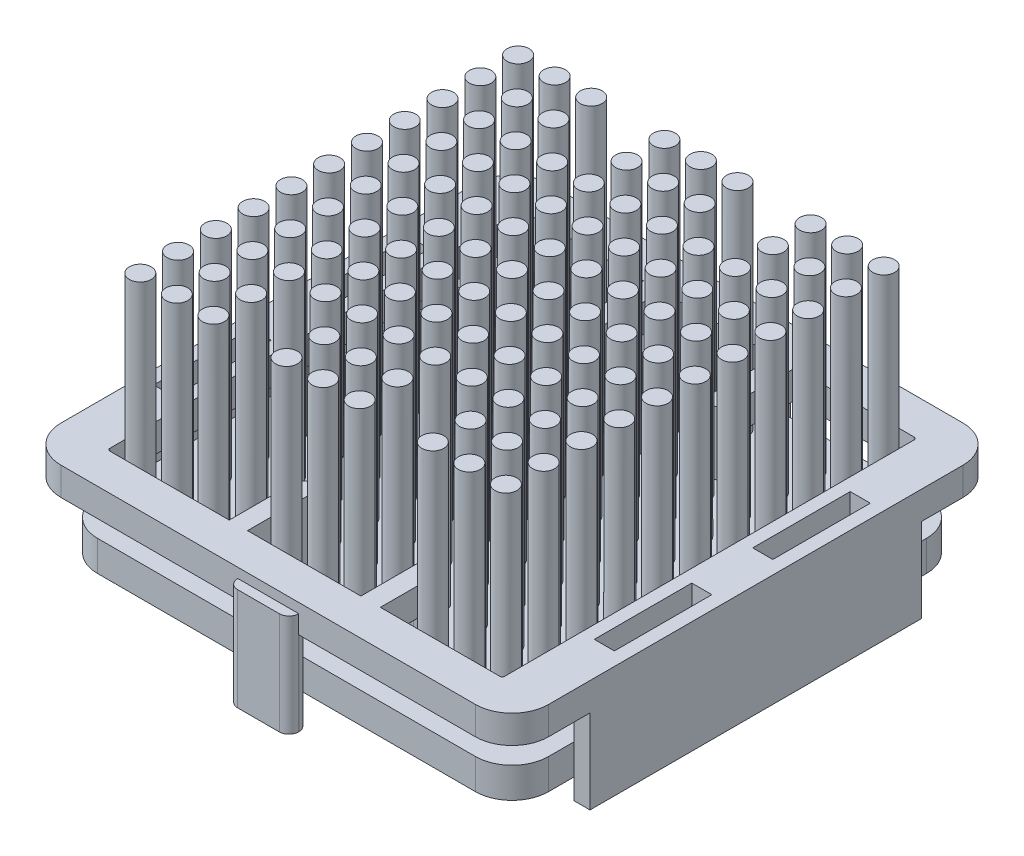
from build123d import *

# Parameters (mm, degrees)
CROQUIS1_W            = 40
CROQUIS1_H            = 40
EXTRUIR1_DEPTH        = 9.2
CORTAR_EXTRUIR1_DEPTH = 16.2
REDONDEO1_R           = 3
REDONDEO2_R           = 0.2
CROQUIS3_W            = 10.806779661
CROQUIS3_H            = 8.662900188
CROQUIS3_W_2          = 12.868801004
CORTAR_EXTRUIR2_DEPTH = 58.2
CROQUIS4_W            = 6.961142498
CROQUIS4_H            = 10.1782172
CROQUIS4_W_2          = 7.337790333
CORTAR_EXTRUIR3_DEPTH = 58.2
REDONDEO3_R           = 0.7
CROQUIS5_W            = 37
CROQUIS5_H            = 37
EXTRUIR2_DEPTH        = 2.5
REDONDEO4_R           = 3
CROQUIS6_R            = 0.9
EXTRUIR3_DEPTH        = 17.6
CROQUIS7_W            = 1.65
CROQUIS7_H            = 8
CORTAR_EXTRUIR4_DEPTH = 12.4
EXTRUIR4_DEPTH        = 8.4
EXTRUIR4_2_DEPTH      = 8.4


with BuildPart() as part:
    # Croquis1 → Extruir1 (new body)
    with BuildSketch(Plane(origin=(0, 0, 0), x_dir=(1, 0, 0), z_dir=(0, 1, 0))):
        Rectangle(CROQUIS1_W, CROQUIS1_H)
    extrude(amount=EXTRUIR1_DEPTH)

    # Croquis2 → Cortar-Extruir1 (cut)
    with BuildSketch(Plane(origin=(0, 9.2, 0), x_dir=(1, 0, 0), z_dir=(0, 1, 0))):
        Polygon((-16.2, 17), (-6.2, 17), (-6.2, 11), (-4.7, 11), (-4.7, 17), (4.6, 17), (4.6, 11), (6.2, 11), (6.2, 17), (16.2, 17), (16.2, -17), (6.2, -17), (6.2, -11), (4.6, -11), (4.6, -17), (-4.7, -17), (-4.7, -11), (-6.2, -11), (-6.2, -17), (-16.2, -17), align=None)
    extrude(amount=-CORTAR_EXTRUIR1_DEPTH, mode=Mode.SUBTRACT)

    # Redondeo1
    redondeo1_edges = [part.edges().sort_by_distance(p)[0] for p in [
        (-20, 4.6, -20),
        (20, 4.6, -20),
        (20, 4.6, 20),
        (-20, 4.6, 20),
    ]]
    fillet(redondeo1_edges, radius=REDONDEO1_R)

    # Redondeo2
    redondeo2_edges = [part.edges().sort_by_distance(p)[0] for p in [
        (-16.2, 4.6, 17),
        (-16.2, 4.6, -17),
        (16.2, 4.6, -17),
        (16.2, 4.6, 17),
    ]]
    fillet(redondeo2_edges, radius=REDONDEO2_R)

    # Croquis3 → Cortar-Extruir2 (cut)
    with BuildSketch(Plane.ZY.offset(20)):
        with Locations((-19.003389831, 2.568549906)):
            Rectangle(CROQUIS3_W, CROQUIS3_H)
        with Locations((20.034400502, 2.568549906)):
            Rectangle(CROQUIS3_W_2, CROQUIS3_H)
    extrude(amount=-CORTAR_EXTRUIR2_DEPTH, mode=Mode.SUBTRACT)

    # Croquis4 → Cortar-Extruir3 (cut)
    with BuildSketch(Plane(origin=(0, 0, -20), x_dir=(-1, 0, 0), z_dir=(0, 0, -1))):
        with Locations((-15.219428751, 1.8108914)):
            Rectangle(CROQUIS4_W, CROQUIS4_H)
        with Locations((15.031104834, 1.8108914)):
            Rectangle(CROQUIS4_W_2, CROQUIS4_H)
    extrude(amount=-CORTAR_EXTRUIR3_DEPTH, mode=Mode.SUBTRACT)

    # Redondeo3
    redondeo3_edges = [part.edges().sort_by_distance(p)[0] for p in [
        (-6.2, 3.45, -13.6),
        (-4.7, 3.45, -13.6),
        (4.6, 3.45, -13.6),
        (6.2, 3.45, -13.6),
        (-6.2, 3.45, 13.6),
        (6.2, 3.45, 13.6),
        (4.6, 3.45, 13.6),
        (-4.7, 3.45, 13.6),
        (-6.2, 4.6, -11),
        (-4.7, 4.6, -11),
        (4.6, 4.6, -11),
        (6.2, 4.6, -11),
        (6.2, 4.6, 11),
        (4.6, 4.6, 11),
        (-4.7, 4.6, 11),
        (-6.2, 4.6, 11),
    ]]
    fillet(redondeo3_edges, radius=REDONDEO3_R)

    # Croquis7 → Cortar-Extruir4 (cut)
    with BuildSketch(Plane(origin=(0, 9.2, 0), x_dir=(1, 0, 0), z_dir=(0, 1, 0))):
        with Locations((18.075, 6.5)):
            Rectangle(CROQUIS7_W, CROQUIS7_H)
        with Locations((18.075, -6.5)):
            Rectangle(CROQUIS7_W, CROQUIS7_H)
        with Locations((-18.075, -6.5)):
            Rectangle(CROQUIS7_W, CROQUIS7_H)
        with Locations((-18.075, 6.5)):
            Rectangle(CROQUIS7_W, CROQUIS7_H)
    extrude(amount=-CORTAR_EXTRUIR4_DEPTH, mode=Mode.SUBTRACT)


with BuildPart() as body_2:
    # Croquis5 → Extruir2 (new body)
    with BuildSketch(Plane.XZ.offset(-1.5)):
        Rectangle(CROQUIS5_W, CROQUIS5_H)
    extrude(amount=-EXTRUIR2_DEPTH)

    # Redondeo4
    redondeo4_edges = [body_2.edges().sort_by_distance(p)[0] for p in [
        (-18.5, 2.75, 18.5),
        (18.5, 2.75, 18.5),
        (18.5, 2.75, -18.5),
        (-18.5, 2.75, -18.5),
    ]]
    fillet(redondeo4_edges, radius=REDONDEO4_R)


with BuildPart() as body_3:
    # Croquis6 → Extruir3 (new body)
    with BuildSketch(Plane(origin=(0, 4, 0), x_dir=(1, 0, 0), z_dir=(0, 1, 0))):
        Circle(CROQUIS6_R)
        with Locations((3, 0)):
            Circle(CROQUIS6_R)
        with Locations((6, 0)):
            Circle(CROQUIS6_R)
        with Locations((9, 0)):
            Circle(CROQUIS6_R)
        with Locations((12, 0)):
            Circle(CROQUIS6_R)
        with Locations((15, 0)):
            Circle(CROQUIS6_R)
        with Locations((0, 3.1)):
            Circle(CROQUIS6_R)
        with Locations((3, 3.1)):
            Circle(CROQUIS6_R)
        with Locations((6, 3.1)):
            Circle(CROQUIS6_R)
        with Locations((9, 3.1)):
            Circle(CROQUIS6_R)
        with Locations((12, 3.1)):
            Circle(CROQUIS6_R)
        with Locations((15, 3.1)):
            Circle(CROQUIS6_R)
        with Locations((0, 6.2)):
            Circle(CROQUIS6_R)
        with Locations((3, 6.2)):
            Circle(CROQUIS6_R)
        with Locations((6, 6.2)):
            Circle(CROQUIS6_R)
        with Locations((9, 6.2)):
            Circle(CROQUIS6_R)
        with Locations((12, 6.2)):
            Circle(CROQUIS6_R)
        with Locations((15, 6.2)):
            Circle(CROQUIS6_R)
        with Locations((0, 9.3)):
            Circle(CROQUIS6_R)
        with Locations((3, 9.3)):
            Circle(CROQUIS6_R)
        with Locations((6, 9.3)):
            Circle(CROQUIS6_R)
        with Locations((9, 9.3)):
            Circle(CROQUIS6_R)
        with Locations((12, 9.3)):
            Circle(CROQUIS6_R)
        with Locations((15, 9.3)):
            Circle(CROQUIS6_R)
        with Locations((0, 12.4)):
            Circle(CROQUIS6_R)
        with Locations((3, 12.4)):
            Circle(CROQUIS6_R)
        with Locations((-15, 15.5)):
            Circle(CROQUIS6_R)
        with Locations((9, 12.4)):
            Circle(CROQUIS6_R)
        with Locations((12, 12.4)):
            Circle(CROQUIS6_R)
        with Locations((15, 12.4)):
            Circle(CROQUIS6_R)
        with Locations((0, 15.5)):
            Circle(CROQUIS6_R)
        with Locations((3, 15.5)):
            Circle(CROQUIS6_R)
        with Locations((-12, 15.5)):
            Circle(CROQUIS6_R)
        with Locations((9, 15.5)):
            Circle(CROQUIS6_R)
        with Locations((12, 15.5)):
            Circle(CROQUIS6_R)
        with Locations((15, 15.5)):
            Circle(CROQUIS6_R)
        with Locations((-9, 15.5)):
            Circle(CROQUIS6_R)
        with Locations((-3, 15.5)):
            Circle(CROQUIS6_R)
        with Locations((-15, 12.4)):
            Circle(CROQUIS6_R)
        with Locations((-12, 12.4)):
            Circle(CROQUIS6_R)
        with Locations((-9, 12.4)):
            Circle(CROQUIS6_R)
        with Locations((-3, 12.4)):
            Circle(CROQUIS6_R)
        with Locations((-15, 9.3)):
            Circle(CROQUIS6_R)
        with Locations((-12, 9.3)):
            Circle(CROQUIS6_R)
        with Locations((-9, 9.3)):
            Circle(CROQUIS6_R)
        with Locations((-6, 9.3)):
            Circle(CROQUIS6_R)
        with Locations((-3, 9.3)):
            Circle(CROQUIS6_R)
        with Locations((-15, 6.2)):
            Circle(CROQUIS6_R)
        with Locations((-12, 6.2)):
            Circle(CROQUIS6_R)
        with Locations((-9, 6.2)):
            Circle(CROQUIS6_R)
        with Locations((-6, 6.2)):
            Circle(CROQUIS6_R)
        with Locations((-3, 6.2)):
            Circle(CROQUIS6_R)
        with Locations((-15, 3.1)):
            Circle(CROQUIS6_R)
        with Locations((-12, 3.1)):
            Circle(CROQUIS6_R)
        with Locations((-9, 3.1)):
            Circle(CROQUIS6_R)
        with Locations((-6, 3.1)):
            Circle(CROQUIS6_R)
        with Locations((-3, 3.1)):
            Circle(CROQUIS6_R)
        with Locations((-15, 0)):
            Circle(CROQUIS6_R)
        with Locations((-12, 0)):
            Circle(CROQUIS6_R)
        with Locations((-9, 0)):
            Circle(CROQUIS6_R)
        with Locations((-6, 0)):
            Circle(CROQUIS6_R)
        with Locations((-3, 0)):
            Circle(CROQUIS6_R)
        with Locations((-3, -3.1)):
            Circle(CROQUIS6_R)
        with Locations((-6, -3.1)):
            Circle(CROQUIS6_R)
        with Locations((-9, -3.1)):
            Circle(CROQUIS6_R)
        with Locations((-12, -3.1)):
            Circle(CROQUIS6_R)
        with Locations((-15, -3.1)):
            Circle(CROQUIS6_R)
        with Locations((-3, -6.2)):
            Circle(CROQUIS6_R)
        with Locations((-6, -6.2)):
            Circle(CROQUIS6_R)
        with Locations((-9, -6.2)):
            Circle(CROQUIS6_R)
        with Locations((-12, -6.2)):
            Circle(CROQUIS6_R)
        with Locations((-15, -6.2)):
            Circle(CROQUIS6_R)
        with Locations((-3, -9.3)):
            Circle(CROQUIS6_R)
        with Locations((-6, -9.3)):
            Circle(CROQUIS6_R)
        with Locations((-9, -9.3)):
            Circle(CROQUIS6_R)
        with Locations((-12, -9.3)):
            Circle(CROQUIS6_R)
        with Locations((-15, -9.3)):
            Circle(CROQUIS6_R)
        with Locations((-3, -12.4)):
            Circle(CROQUIS6_R)
        with Locations((-9, -12.4)):
            Circle(CROQUIS6_R)
        with Locations((-12, -12.4)):
            Circle(CROQUIS6_R)
        with Locations((-15, -12.4)):
            Circle(CROQUIS6_R)
        with Locations((-3, -15.5)):
            Circle(CROQUIS6_R)
        with Locations((-9, -15.5)):
            Circle(CROQUIS6_R)
        with Locations((15, -15.5)):
            Circle(CROQUIS6_R)
        with Locations((12, -15.5)):
            Circle(CROQUIS6_R)
        with Locations((9, -15.5)):
            Circle(CROQUIS6_R)
        with Locations((-12, -15.5)):
            Circle(CROQUIS6_R)
        with Locations((3, -15.5)):
            Circle(CROQUIS6_R)
        with Locations((0, -15.5)):
            Circle(CROQUIS6_R)
        with Locations((15, -12.4)):
            Circle(CROQUIS6_R)
        with Locations((12, -12.4)):
            Circle(CROQUIS6_R)
        with Locations((9, -12.4)):
            Circle(CROQUIS6_R)
        with Locations((-15, -15.5)):
            Circle(CROQUIS6_R)
        with Locations((3, -12.4)):
            Circle(CROQUIS6_R)
        with Locations((0, -12.4)):
            Circle(CROQUIS6_R)
        with Locations((15, -9.3)):
            Circle(CROQUIS6_R)
        with Locations((12, -9.3)):
            Circle(CROQUIS6_R)
        with Locations((9, -9.3)):
            Circle(CROQUIS6_R)
        with Locations((6, -9.3)):
            Circle(CROQUIS6_R)
        with Locations((3, -9.3)):
            Circle(CROQUIS6_R)
        with Locations((0, -9.3)):
            Circle(CROQUIS6_R)
        with Locations((15, -6.2)):
            Circle(CROQUIS6_R)
        with Locations((12, -6.2)):
            Circle(CROQUIS6_R)
        with Locations((9, -6.2)):
            Circle(CROQUIS6_R)
        with Locations((6, -6.2)):
            Circle(CROQUIS6_R)
        with Locations((3, -6.2)):
            Circle(CROQUIS6_R)
        with Locations((0, -6.2)):
            Circle(CROQUIS6_R)
        with Locations((15, -3.1)):
            Circle(CROQUIS6_R)
        with Locations((12, -3.1)):
            Circle(CROQUIS6_R)
        with Locations((9, -3.1)):
            Circle(CROQUIS6_R)
        with Locations((6, -3.1)):
            Circle(CROQUIS6_R)
        with Locations((3, -3.1)):
            Circle(CROQUIS6_R)
        with Locations((0, -3.1)):
            Circle(CROQUIS6_R)
    extrude(amount=EXTRUIR3_DEPTH)

    # Combinar1: union body 2
    add(body_2.part)


with BuildPart() as body_3_2:
    # Croquis8 → Extruir4 (new body)
    with BuildSketch(Plane.XZ):
        with BuildLine():
            Line((-1.71, 20.8), (1.71, 20.8))
            ThreePointArc((1.71, 20.8), (2.268614357, 20.568614357), (2.5, 20.01))
            Line((2.5, 20.01), (2.5, 19.99))
            ThreePointArc((2.5, 19.99), (2.268614357, 19.431385643), (1.71, 19.2))
            Line((1.71, 19.2), (-1.71, 19.2))
            ThreePointArc((-1.71, 19.2), (-2.268614357, 19.431385643), (-2.5, 19.99))
            Line((-2.5, 19.99), (-2.5, 20.01))
            ThreePointArc((-2.5, 20.01), (-2.268614357, 20.568614357), (-1.71, 20.8))
        make_face()
    extrude(amount=-EXTRUIR4_DEPTH)


with BuildPart() as body_4:
    # Croquis8 → Extruir4 2 (new body)
    with BuildSketch(Plane.XZ):
        with BuildLine():
            Line((2.5, -20.01), (2.5, -19.99))
            ThreePointArc((2.5, -19.99), (2.268614357, -19.431385643), (1.71, -19.2))
            Line((1.71, -19.2), (-1.71, -19.2))
            ThreePointArc((-1.71, -19.2), (-2.268614357, -19.431385643), (-2.5, -19.99))
            Line((-2.5, -19.99), (-2.5, -20.01))
            ThreePointArc((-2.5, -20.01), (-2.268614357, -20.568614357), (-1.71, -20.8))
            Line((-1.71, -20.8), (1.71, -20.8))
            ThreePointArc((1.71, -20.8), (2.268614357, -20.568614357), (2.5, -20.01))
        make_face()
    extrude(amount=-EXTRUIR4_2_DEPTH)


with BuildPart() as part_1:
    add(part.part)

    # Combinar2: union body 3 2, body 4
    add(body_3_2.part)
    add(body_4.part)


solid = Compound([body_3.part, part_1.part])
